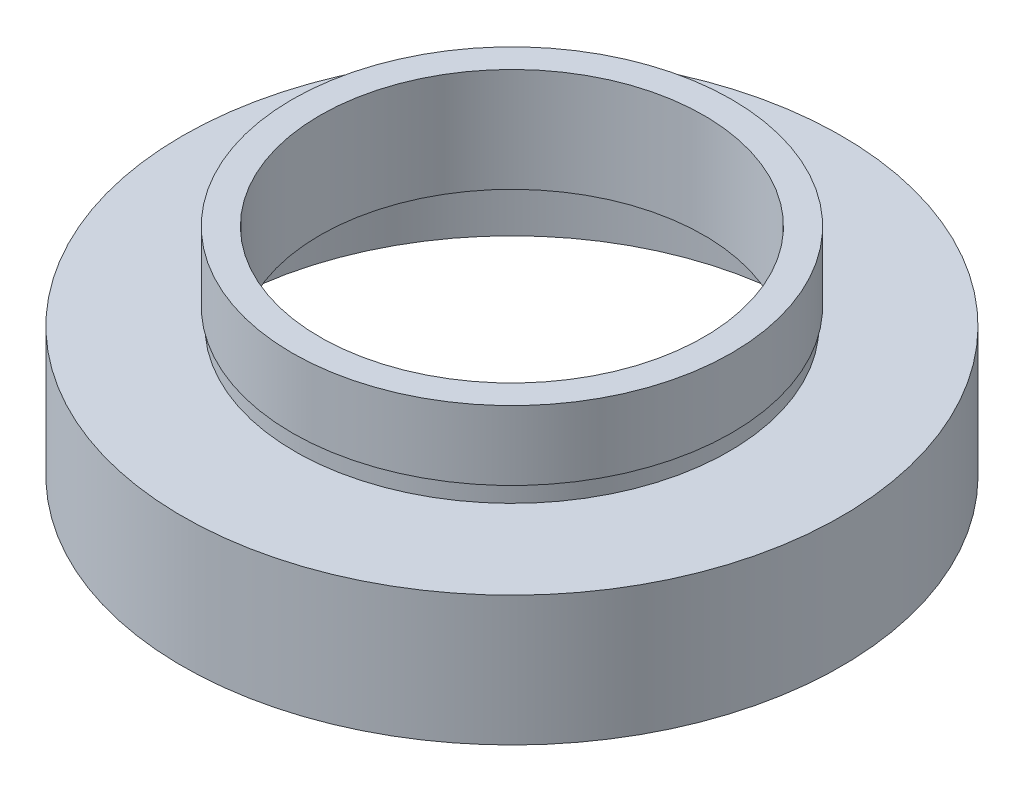
from build123d import *


with BuildPart() as part:
    # 草图1 → 旋转1 (revolve)
    with BuildSketch(Plane.XY, mode=Mode.PRIVATE) as revolve_1_sk:
        Polygon((17, 0), (17, 5.5), (17.6, 5.5), (17.6, 6.5), (11.1, 6.5), (11.1, 12.5), (12.7, 12.5), (12.7, 8.5), (12.55, 8.5), (12.55, 7.5), (19.05, 7.5), (19.05, 0), align=None)
    revolve(revolve_1_sk.sketch.rotate(Axis((0, 16.886018237, 0), (0, -1, 0)), 180), axis=Axis((0, 16.886018237, 0), (0, -1, 0)))  # turned: the seam where the file's is


solid = part.part
